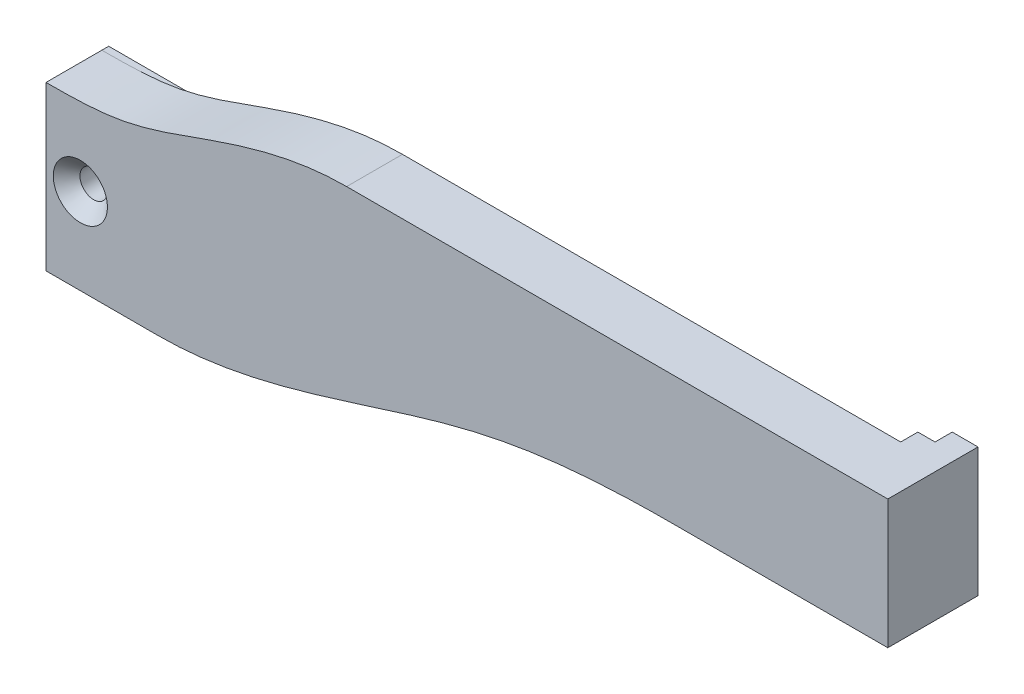
from build123d import *

# Parameters (mm, degrees)
SKETCH1_W                                       = 98
SKETCH1_H                                       = 26
BOSS_EXTRUDE1_DEPTH                             = 6.5
BOSS_EXTRUDE2_DEPTH                             = 2
CUT_EXTRUDE2_DEPTH                              = 3
CUT_EXTRUDE2_DEPTH_BACK                         = 7.5
BOSS_EXTRUDE3_DEPTH                             = 0.8
SKETCH6_W                                       = 3
SKETCH6_H                                       = 15
BOSS_EXTRUDE4_DEPTH                             = 2
CHAMFER1_SIZE                                   = 0.8
CSK_FOR_M3_FLAT_HEAD_MACHINE_SCREW1_D           = 3.2
CSK_FOR_M3_FLAT_HEAD_MACHINE_SCREW1_CSINK_D     = 6.3
CSK_FOR_M3_FLAT_HEAD_MACHINE_SCREW1_CSINK_ANGLE = 90
SKETCH12_R                                      = 2
CUT_EXTRUDE3_DEPTH                              = 5


with BuildPart() as part:
    # Sketch1 → Boss-Extrude1 (new body)
    with BuildSketch(Plane.XY):
        with Locations((-4.722668085, 59.458490272)):
            Rectangle(SKETCH1_W, SKETCH1_H)
    extrude(amount=BOSS_EXTRUDE1_DEPTH)

    # Sketch3 → Boss-Extrude2 (add)
    with BuildSketch(Plane(origin=(0, 0, 0), x_dir=(-1, 0, 0), z_dir=(0, 0, -1))):
        Polygon((-44.277331915, 72.458490272), (-44.277331915, 57.458490272), (-42.277331915, 57.458490272), (-42.277331915, 70.458490272), (-39.277331915, 70.458490272), (-39.277331915, 72.458490272), align=None)
    extrude(amount=BOSS_EXTRUDE2_DEPTH)

    # Sketch4 → Cut-Extrude2 (cut, two sides)
    with BuildSketch(Plane(origin=(0, 0, 0), x_dir=(-1, 0, 0), z_dir=(0, 0, -1))) as cut_extrude2_sk:
        with BuildLine():
            Line((-44.277331915, 57.458490272), (-19.277331915, 57.458490272))
            add(Edge.make_bspline(
                [(-19.277331915, 57.458490272), (-7.832942992, 57.458490272), (8.904121741, 55.154017843), (29.529578832, 46.458490272), (40.722668085, 46.458490272)],
                knots=[0, 0, 0, 0, 0.448705595, 1, 1, 1, 1], degree=3))
            Line((40.722668085, 46.458490272), (-44.277331915, 46.458490272))
            Line((-44.277331915, 46.458490272), (-44.277331915, 57.458490272))
        make_face()
        with BuildLine():
            Line((18.722668085, 72.458490272), (53.722668085, 72.458490272))
            Line((53.722668085, 72.458490272), (53.722668085, 65.458490272))
            add(Edge.make_bspline(
                [(18.722668085, 72.458490272), (24.237785364, 72.458490272), (33.045165364, 69.996464802), (44.178399876, 65.548896557), (50.961091511, 65.458490272), (53.722668085, 65.458490272)],
                knots=[0, 0, 0, 0, 0.451492406, 0.761184281, 1, 1, 1, 1], degree=3))
        make_face()
    extrude(amount=CUT_EXTRUDE2_DEPTH, mode=Mode.SUBTRACT)
    extrude(cut_extrude2_sk.sketch, amount=-CUT_EXTRUDE2_DEPTH_BACK, mode=Mode.SUBTRACT)

    # Sketch5 → Boss-Extrude3 (add)
    with BuildSketch(Plane(origin=(0, 0, 0), x_dir=(-1, 0, 0), z_dir=(0, 0, -1))):
        with BuildLine():
            Line((43.222668085, 46.458490272), (40.722668085, 46.458490272))
            Line((40.722668085, 46.458490272), (40.722668085, 64.958490272))
            Line((40.722668085, 64.958490272), (41.222668085, 65.458490272))
            Line((41.222668085, 65.458490272), (53.722668085, 65.458490272))
            Line((53.722668085, 65.458490272), (53.722668085, 62.958490272))
            Line((53.722668085, 62.958490272), (44.122668085, 62.958490272))
            ThreePointArc((44.122668085, 62.958490272), (43.486271982, 62.694886375), (43.222668085, 62.058490272))
            Line((43.222668085, 62.058490272), (43.222668085, 46.458490272))
        make_face()
    extrude(amount=BOSS_EXTRUDE3_DEPTH)

    # Sketch6 → Boss-Extrude4 (add)
    with BuildSketch(Plane(origin=(0, 0, -2), x_dir=(-1, 0, 0), z_dir=(0, 0, -1))):
        with Locations((-42.777331915, 64.958490272)):
            Rectangle(SKETCH6_W, SKETCH6_H)
    extrude(amount=BOSS_EXTRUDE4_DEPTH)

    # Chamfer1
    chamfer1_edges = [part.edges().sort_by_distance(p)[0] for p in [
        (42.277331915, 63.958490272, -2),
    ]]
    chamfer(chamfer1_edges, length=CHAMFER1_SIZE)

    # CSK for M3 Flat Head Machine Screw1 (through all)
    with Locations(Plane.XY.offset(6.5)):
        with Locations((-49.722668085, 56.458490272)):
            CounterSinkHole(CSK_FOR_M3_FLAT_HEAD_MACHINE_SCREW1_D / 2, CSK_FOR_M3_FLAT_HEAD_MACHINE_SCREW1_CSINK_D / 2, counter_sink_angle=CSK_FOR_M3_FLAT_HEAD_MACHINE_SCREW1_CSINK_ANGLE)

    # Sketch12 → Cut-Extrude3 (cut)
    with BuildSketch(Plane(origin=(0, 0, 0), x_dir=(-1, 0, 0), z_dir=(0, 0, -1))):
        with Locations((19.647668085, 68.883490272)):
            Circle(SKETCH12_R)
    extrude(amount=-CUT_EXTRUDE3_DEPTH, mode=Mode.SUBTRACT)


solid = part.part
